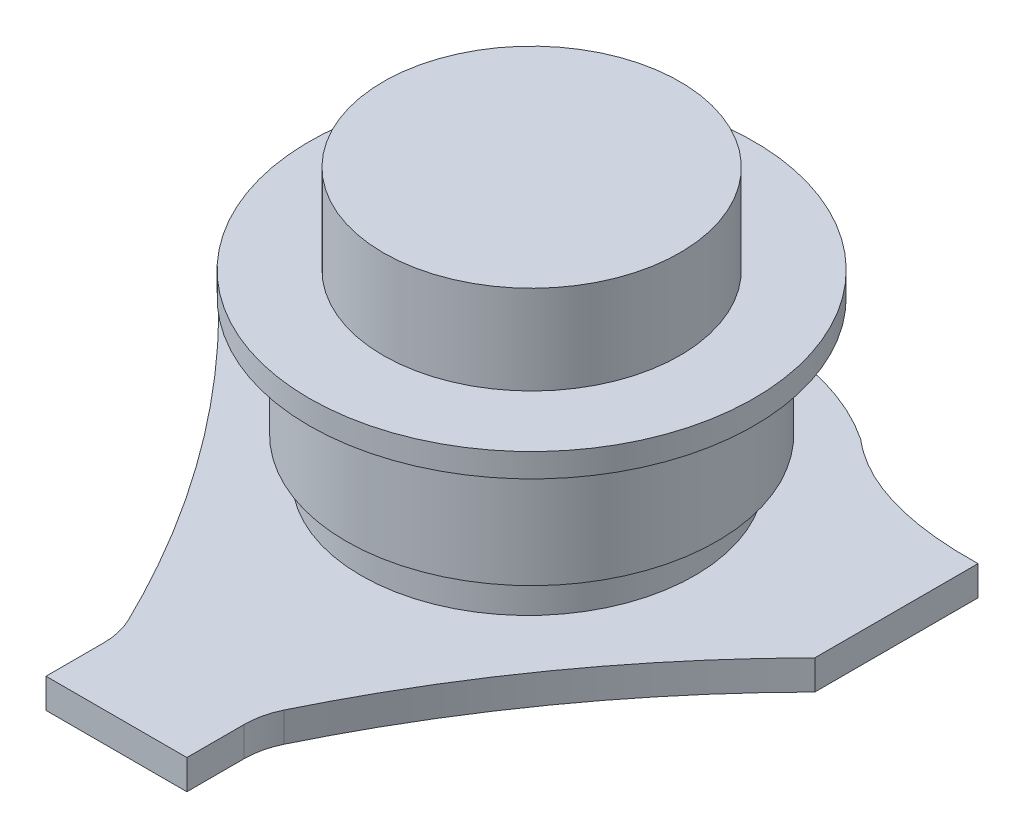
from build123d import *

# Parameters (mm, degrees)
BOSS_EXTRUDE1_DEPTH = 5.08
FILLET1_R           = 12.7
FILLET2_R           = 12.7
SKETCH2_R           = 28.575
BOSS_EXTRUDE2_DEPTH = 6.35
SKETCH3_R           = 31.75
BOSS_EXTRUDE3_DEPTH = 20.32
SKETCH4_R           = 38.1
BOSS_EXTRUDE4_DEPTH = 4.064
SKETCH5_R           = 25.4
BOSS_EXTRUDE5_DEPTH = 15.24


with BuildPart() as part:
    # Sketch1 → Boss-Extrude1 (new body)
    with BuildSketch(Plane(origin=(0, 0, 0), x_dir=(1, 0, 0), z_dir=(0, 1, 0))):
        with BuildLine():
            Line((51.054, -2.54), (51.054, 0))
            Line((51.054, 0), (51.054, 25.4))
            add(Edge.make_bspline(
                [(51.054, 25.4), (35.593374206, 25.086699202), (25.873960254, 31.339237081)],
                knots=[0, 0, 0, 0.413959763, 0.413959763, 0.413959763], degree=2))
            add(Edge.make_bspline(
                [(25.873960254, 31.339237081), (24.125496917, 32.46403054), (22.562829629, 33.80130647)],
                knots=[0.413959763, 0.413959763, 0.413959763, 0.488428602, 0.488428602, 0.488428602], degree=2))
            ThreePointArc((22.562829629, 33.80130647), (0, 40.64), (-22.562829629, 33.80130647))
            add(Edge.make_bspline(
                [(-25.873960254, 31.339237081), (-24.125496917, 32.46403054), (-22.562829629, 33.80130647)],
                knots=[0.413959763, 0.413959763, 0.413959763, 0.488428602, 0.488428602, 0.488428602], degree=2))
            add(Edge.make_bspline(
                [(-51.054, 25.4), (-35.593374206, 25.086699202), (-25.873960254, 31.339237081)],
                knots=[0, 0, 0, 0.413959763, 0.413959763, 0.413959763], degree=2))
            Line((-51.054, 25.4), (-51.054, 0))
            Line((-51.054, 0), (-51.054, -2.54))
            add(Edge.make_bspline(
                [(-51.054, -2.54), (-42.130232366, -11.547896864), (-34.503914612, -21.472994119)],
                knots=[0, 0, 0, 0.367111941, 0.367111941, 0.367111941], degree=2))
            add(Edge.make_bspline(
                [(-34.503914612, -21.472994119), (-32.482868864, -24.103237999), (-30.552942986, -26.797896838)],
                knots=[0.367111941, 0.367111941, 0.367111941, 0.46440005, 0.46440005, 0.46440005], degree=2))
            add(Edge.make_bspline(
                [(-30.552942986, -26.797896838), (-19.928127461, -41.632794577), (-12.065, -58.42)],
                knots=[0.46440005, 0.46440005, 0.46440005, 1, 1, 1], degree=2))
            Line((-12.065, -58.42), (-12.065, -71.12))
            Line((-12.065, -71.12), (12.065, -71.12))
            Line((12.065, -71.12), (12.065, -58.42))
            add(Edge.make_bspline(
                [(30.552942986, -26.797896838), (19.928127461, -41.632794577), (12.065, -58.42)],
                knots=[0.46440005, 0.46440005, 0.46440005, 1, 1, 1], degree=2))
            add(Edge.make_bspline(
                [(34.503914612, -21.472994119), (32.482868864, -24.103237999), (30.552942986, -26.797896838)],
                knots=[0.367111941, 0.367111941, 0.367111941, 0.46440005, 0.46440005, 0.46440005], degree=2))
            add(Edge.make_bspline(
                [(51.054, -2.54), (42.130232366, -11.547896864), (34.503914612, -21.472994119)],
                knots=[0, 0, 0, 0.367111941, 0.367111941, 0.367111941], degree=2))
        make_face()
    extrude(amount=BOSS_EXTRUDE1_DEPTH)

    # Fillet1
    fillet1_edges = [part.edges().sort_by_distance(p)[0] for p in [
        (-12.065, 2.54, 58.42),
    ]]
    fillet(fillet1_edges, radius=FILLET1_R)

    # Fillet2
    fillet2_edges = [part.edges().sort_by_distance(p)[0] for p in [
        (12.065, 2.54, 58.42),
    ]]
    fillet(fillet2_edges, radius=FILLET2_R)

    # Sketch2 → Boss-Extrude2 (add)
    with BuildSketch(Plane(origin=(0, 5.08, 0), x_dir=(1, 0, 0), z_dir=(0, 1, 0))):
        with Locations((0, -0.635)):
            Circle(SKETCH2_R)
    extrude(amount=BOSS_EXTRUDE2_DEPTH)

    # Sketch3 → Boss-Extrude3 (add)
    with BuildSketch(Plane(origin=(0, 11.43, 0), x_dir=(1, 0, 0), z_dir=(0, 1, 0))):
        Circle(SKETCH3_R)
    extrude(amount=BOSS_EXTRUDE3_DEPTH)

    # Sketch4 → Boss-Extrude4 (add)
    with BuildSketch(Plane(origin=(0, 31.75, 0), x_dir=(1, 0, 0), z_dir=(0, 1, 0))):
        Circle(SKETCH4_R)
    extrude(amount=BOSS_EXTRUDE4_DEPTH)

    # Sketch5 → Boss-Extrude5 (add)
    with BuildSketch(Plane(origin=(0, 35.814, 0), x_dir=(1, 0, 0), z_dir=(0, 1, 0))):
        Circle(SKETCH5_R)
    extrude(amount=BOSS_EXTRUDE5_DEPTH)


solid = part.part
